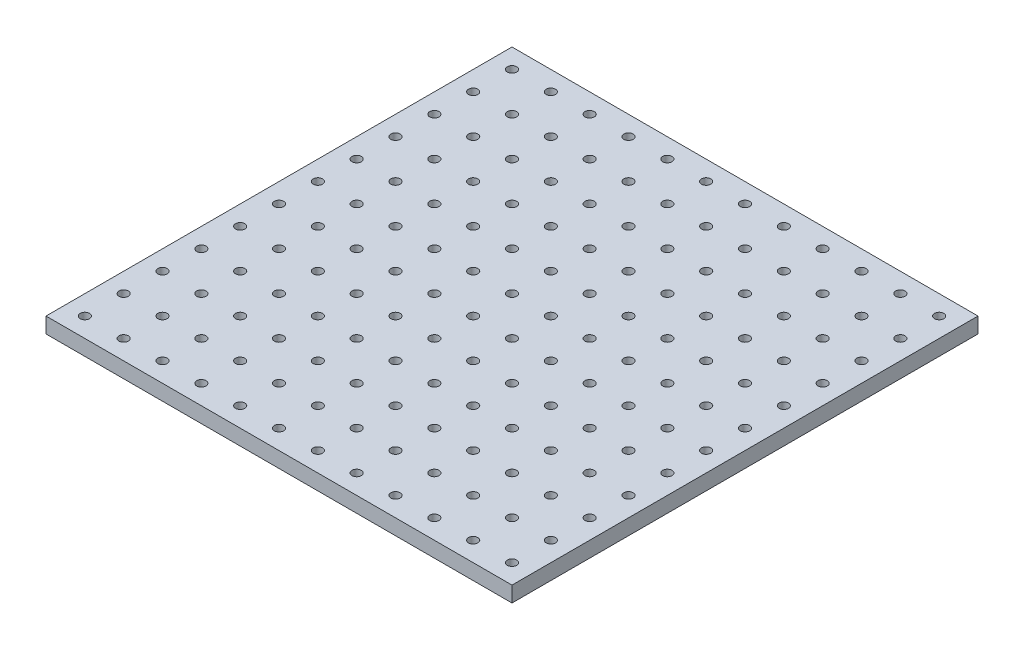
from build123d import *

# Parameters (mm, degrees)
SKETCH_2_W      = 300
SKETCH_2_H      = 300
SKETCH_2_R      = 3
EXTRUDE_2_DEPTH = 10


with BuildPart() as part:
    # 스케치2 → 보스-돌출2 (new body)
    with BuildSketch(Plane(origin=(0, 0, 0), x_dir=(1, 0, 0), z_dir=(0, 1, 0))):
        Rectangle(SKETCH_2_W, SKETCH_2_H)
        with Locations((-137.5, -137.5)):
            Circle(SKETCH_2_R, mode=Mode.SUBTRACT)
        with Locations((-112.5, -137.5)):
            Circle(SKETCH_2_R, mode=Mode.SUBTRACT)
        with Locations((-87.5, -137.5)):
            Circle(SKETCH_2_R, mode=Mode.SUBTRACT)
        with Locations((-62.5, -137.5)):
            Circle(SKETCH_2_R, mode=Mode.SUBTRACT)
        with Locations((-37.5, -137.5)):
            Circle(SKETCH_2_R, mode=Mode.SUBTRACT)
        with Locations((-12.5, -137.5)):
            Circle(SKETCH_2_R, mode=Mode.SUBTRACT)
        with Locations((12.5, -137.5)):
            Circle(SKETCH_2_R, mode=Mode.SUBTRACT)
        with Locations((37.5, -137.5)):
            Circle(SKETCH_2_R, mode=Mode.SUBTRACT)
        with Locations((62.5, -137.5)):
            Circle(SKETCH_2_R, mode=Mode.SUBTRACT)
        with Locations((87.5, -137.5)):
            Circle(SKETCH_2_R, mode=Mode.SUBTRACT)
        with Locations((112.5, -137.5)):
            Circle(SKETCH_2_R, mode=Mode.SUBTRACT)
        with Locations((137.5, -137.5)):
            Circle(SKETCH_2_R, mode=Mode.SUBTRACT)
        with Locations((-112.5, -112.5)):
            Circle(SKETCH_2_R, mode=Mode.SUBTRACT)
        with Locations((-87.5, -112.5)):
            Circle(SKETCH_2_R, mode=Mode.SUBTRACT)
        with Locations((-62.5, -112.5)):
            Circle(SKETCH_2_R, mode=Mode.SUBTRACT)
        with Locations((-37.5, -112.5)):
            Circle(SKETCH_2_R, mode=Mode.SUBTRACT)
        with Locations((-12.5, -112.5)):
            Circle(SKETCH_2_R, mode=Mode.SUBTRACT)
        with Locations((12.5, -112.5)):
            Circle(SKETCH_2_R, mode=Mode.SUBTRACT)
        with Locations((37.5, -112.5)):
            Circle(SKETCH_2_R, mode=Mode.SUBTRACT)
        with Locations((62.5, -112.5)):
            Circle(SKETCH_2_R, mode=Mode.SUBTRACT)
        with Locations((87.5, -112.5)):
            Circle(SKETCH_2_R, mode=Mode.SUBTRACT)
        with Locations((112.5, -112.5)):
            Circle(SKETCH_2_R, mode=Mode.SUBTRACT)
        with Locations((137.5, -112.5)):
            Circle(SKETCH_2_R, mode=Mode.SUBTRACT)
        with Locations((-112.5, -87.5)):
            Circle(SKETCH_2_R, mode=Mode.SUBTRACT)
        with Locations((-87.5, -87.5)):
            Circle(SKETCH_2_R, mode=Mode.SUBTRACT)
        with Locations((-62.5, -87.5)):
            Circle(SKETCH_2_R, mode=Mode.SUBTRACT)
        with Locations((-37.5, -87.5)):
            Circle(SKETCH_2_R, mode=Mode.SUBTRACT)
        with Locations((-12.5, -87.5)):
            Circle(SKETCH_2_R, mode=Mode.SUBTRACT)
        with Locations((12.5, -87.5)):
            Circle(SKETCH_2_R, mode=Mode.SUBTRACT)
        with Locations((37.5, -87.5)):
            Circle(SKETCH_2_R, mode=Mode.SUBTRACT)
        with Locations((62.5, -87.5)):
            Circle(SKETCH_2_R, mode=Mode.SUBTRACT)
        with Locations((87.5, -87.5)):
            Circle(SKETCH_2_R, mode=Mode.SUBTRACT)
        with Locations((112.5, -87.5)):
            Circle(SKETCH_2_R, mode=Mode.SUBTRACT)
        with Locations((137.5, -87.5)):
            Circle(SKETCH_2_R, mode=Mode.SUBTRACT)
        with Locations((-112.5, -62.5)):
            Circle(SKETCH_2_R, mode=Mode.SUBTRACT)
        with Locations((-87.5, -62.5)):
            Circle(SKETCH_2_R, mode=Mode.SUBTRACT)
        with Locations((-62.5, -62.5)):
            Circle(SKETCH_2_R, mode=Mode.SUBTRACT)
        with Locations((-37.5, -62.5)):
            Circle(SKETCH_2_R, mode=Mode.SUBTRACT)
        with Locations((-12.5, -62.5)):
            Circle(SKETCH_2_R, mode=Mode.SUBTRACT)
        with Locations((12.5, -62.5)):
            Circle(SKETCH_2_R, mode=Mode.SUBTRACT)
        with Locations((37.5, -62.5)):
            Circle(SKETCH_2_R, mode=Mode.SUBTRACT)
        with Locations((62.5, -62.5)):
            Circle(SKETCH_2_R, mode=Mode.SUBTRACT)
        with Locations((87.5, -62.5)):
            Circle(SKETCH_2_R, mode=Mode.SUBTRACT)
        with Locations((112.5, -62.5)):
            Circle(SKETCH_2_R, mode=Mode.SUBTRACT)
        with Locations((137.5, -62.5)):
            Circle(SKETCH_2_R, mode=Mode.SUBTRACT)
        with Locations((-112.5, -37.5)):
            Circle(SKETCH_2_R, mode=Mode.SUBTRACT)
        with Locations((-87.5, -37.5)):
            Circle(SKETCH_2_R, mode=Mode.SUBTRACT)
        with Locations((-62.5, -37.5)):
            Circle(SKETCH_2_R, mode=Mode.SUBTRACT)
        with Locations((-37.5, -37.5)):
            Circle(SKETCH_2_R, mode=Mode.SUBTRACT)
        with Locations((-12.5, -37.5)):
            Circle(SKETCH_2_R, mode=Mode.SUBTRACT)
        with Locations((12.5, -37.5)):
            Circle(SKETCH_2_R, mode=Mode.SUBTRACT)
        with Locations((37.5, -37.5)):
            Circle(SKETCH_2_R, mode=Mode.SUBTRACT)
        with Locations((62.5, -37.5)):
            Circle(SKETCH_2_R, mode=Mode.SUBTRACT)
        with Locations((87.5, -37.5)):
            Circle(SKETCH_2_R, mode=Mode.SUBTRACT)
        with Locations((112.5, -37.5)):
            Circle(SKETCH_2_R, mode=Mode.SUBTRACT)
        with Locations((137.5, -37.5)):
            Circle(SKETCH_2_R, mode=Mode.SUBTRACT)
        with Locations((-112.5, -12.5)):
            Circle(SKETCH_2_R, mode=Mode.SUBTRACT)
        with Locations((-87.5, -12.5)):
            Circle(SKETCH_2_R, mode=Mode.SUBTRACT)
        with Locations((-62.5, -12.5)):
            Circle(SKETCH_2_R, mode=Mode.SUBTRACT)
        with Locations((-37.5, -12.5)):
            Circle(SKETCH_2_R, mode=Mode.SUBTRACT)
        with Locations((-12.5, -12.5)):
            Circle(SKETCH_2_R, mode=Mode.SUBTRACT)
        with Locations((12.5, -12.5)):
            Circle(SKETCH_2_R, mode=Mode.SUBTRACT)
        with Locations((37.5, -12.5)):
            Circle(SKETCH_2_R, mode=Mode.SUBTRACT)
        with Locations((62.5, -12.5)):
            Circle(SKETCH_2_R, mode=Mode.SUBTRACT)
        with Locations((87.5, -12.5)):
            Circle(SKETCH_2_R, mode=Mode.SUBTRACT)
        with Locations((112.5, -12.5)):
            Circle(SKETCH_2_R, mode=Mode.SUBTRACT)
        with Locations((137.5, -12.5)):
            Circle(SKETCH_2_R, mode=Mode.SUBTRACT)
        with Locations((-112.5, 12.5)):
            Circle(SKETCH_2_R, mode=Mode.SUBTRACT)
        with Locations((-87.5, 12.5)):
            Circle(SKETCH_2_R, mode=Mode.SUBTRACT)
        with Locations((-62.5, 12.5)):
            Circle(SKETCH_2_R, mode=Mode.SUBTRACT)
        with Locations((-37.5, 12.5)):
            Circle(SKETCH_2_R, mode=Mode.SUBTRACT)
        with Locations((-12.5, 12.5)):
            Circle(SKETCH_2_R, mode=Mode.SUBTRACT)
        with Locations((12.5, 12.5)):
            Circle(SKETCH_2_R, mode=Mode.SUBTRACT)
        with Locations((37.5, 12.5)):
            Circle(SKETCH_2_R, mode=Mode.SUBTRACT)
        with Locations((62.5, 12.5)):
            Circle(SKETCH_2_R, mode=Mode.SUBTRACT)
        with Locations((87.5, 12.5)):
            Circle(SKETCH_2_R, mode=Mode.SUBTRACT)
        with Locations((112.5, 12.5)):
            Circle(SKETCH_2_R, mode=Mode.SUBTRACT)
        with Locations((137.5, 12.5)):
            Circle(SKETCH_2_R, mode=Mode.SUBTRACT)
        with Locations((-112.5, 37.5)):
            Circle(SKETCH_2_R, mode=Mode.SUBTRACT)
        with Locations((-87.5, 37.5)):
            Circle(SKETCH_2_R, mode=Mode.SUBTRACT)
        with Locations((-62.5, 37.5)):
            Circle(SKETCH_2_R, mode=Mode.SUBTRACT)
        with Locations((-37.5, 37.5)):
            Circle(SKETCH_2_R, mode=Mode.SUBTRACT)
        with Locations((-12.5, 37.5)):
            Circle(SKETCH_2_R, mode=Mode.SUBTRACT)
        with Locations((12.5, 37.5)):
            Circle(SKETCH_2_R, mode=Mode.SUBTRACT)
        with Locations((37.5, 37.5)):
            Circle(SKETCH_2_R, mode=Mode.SUBTRACT)
        with Locations((62.5, 37.5)):
            Circle(SKETCH_2_R, mode=Mode.SUBTRACT)
        with Locations((87.5, 37.5)):
            Circle(SKETCH_2_R, mode=Mode.SUBTRACT)
        with Locations((112.5, 37.5)):
            Circle(SKETCH_2_R, mode=Mode.SUBTRACT)
        with Locations((137.5, 37.5)):
            Circle(SKETCH_2_R, mode=Mode.SUBTRACT)
        with Locations((-112.5, 62.5)):
            Circle(SKETCH_2_R, mode=Mode.SUBTRACT)
        with Locations((-87.5, 62.5)):
            Circle(SKETCH_2_R, mode=Mode.SUBTRACT)
        with Locations((-62.5, 62.5)):
            Circle(SKETCH_2_R, mode=Mode.SUBTRACT)
        with Locations((-37.5, 62.5)):
            Circle(SKETCH_2_R, mode=Mode.SUBTRACT)
        with Locations((-12.5, 62.5)):
            Circle(SKETCH_2_R, mode=Mode.SUBTRACT)
        with Locations((12.5, 62.5)):
            Circle(SKETCH_2_R, mode=Mode.SUBTRACT)
        with Locations((37.5, 62.5)):
            Circle(SKETCH_2_R, mode=Mode.SUBTRACT)
        with Locations((62.5, 62.5)):
            Circle(SKETCH_2_R, mode=Mode.SUBTRACT)
        with Locations((87.5, 62.5)):
            Circle(SKETCH_2_R, mode=Mode.SUBTRACT)
        with Locations((112.5, 62.5)):
            Circle(SKETCH_2_R, mode=Mode.SUBTRACT)
        with Locations((137.5, 62.5)):
            Circle(SKETCH_2_R, mode=Mode.SUBTRACT)
        with Locations((-112.5, 87.5)):
            Circle(SKETCH_2_R, mode=Mode.SUBTRACT)
        with Locations((-87.5, 87.5)):
            Circle(SKETCH_2_R, mode=Mode.SUBTRACT)
        with Locations((-62.5, 87.5)):
            Circle(SKETCH_2_R, mode=Mode.SUBTRACT)
        with Locations((-37.5, 87.5)):
            Circle(SKETCH_2_R, mode=Mode.SUBTRACT)
        with Locations((-12.5, 87.5)):
            Circle(SKETCH_2_R, mode=Mode.SUBTRACT)
        with Locations((12.5, 87.5)):
            Circle(SKETCH_2_R, mode=Mode.SUBTRACT)
        with Locations((37.5, 87.5)):
            Circle(SKETCH_2_R, mode=Mode.SUBTRACT)
        with Locations((62.5, 87.5)):
            Circle(SKETCH_2_R, mode=Mode.SUBTRACT)
        with Locations((87.5, 87.5)):
            Circle(SKETCH_2_R, mode=Mode.SUBTRACT)
        with Locations((112.5, 87.5)):
            Circle(SKETCH_2_R, mode=Mode.SUBTRACT)
        with Locations((137.5, 87.5)):
            Circle(SKETCH_2_R, mode=Mode.SUBTRACT)
        with Locations((-112.5, 112.5)):
            Circle(SKETCH_2_R, mode=Mode.SUBTRACT)
        with Locations((-87.5, 112.5)):
            Circle(SKETCH_2_R, mode=Mode.SUBTRACT)
        with Locations((-62.5, 112.5)):
            Circle(SKETCH_2_R, mode=Mode.SUBTRACT)
        with Locations((-37.5, 112.5)):
            Circle(SKETCH_2_R, mode=Mode.SUBTRACT)
        with Locations((-12.5, 112.5)):
            Circle(SKETCH_2_R, mode=Mode.SUBTRACT)
        with Locations((12.5, 112.5)):
            Circle(SKETCH_2_R, mode=Mode.SUBTRACT)
        with Locations((37.5, 112.5)):
            Circle(SKETCH_2_R, mode=Mode.SUBTRACT)
        with Locations((62.5, 112.5)):
            Circle(SKETCH_2_R, mode=Mode.SUBTRACT)
        with Locations((87.5, 112.5)):
            Circle(SKETCH_2_R, mode=Mode.SUBTRACT)
        with Locations((112.5, 112.5)):
            Circle(SKETCH_2_R, mode=Mode.SUBTRACT)
        with Locations((137.5, 112.5)):
            Circle(SKETCH_2_R, mode=Mode.SUBTRACT)
        with Locations((-112.5, 137.5)):
            Circle(SKETCH_2_R, mode=Mode.SUBTRACT)
        with Locations((-87.5, 137.5)):
            Circle(SKETCH_2_R, mode=Mode.SUBTRACT)
        with Locations((-62.5, 137.5)):
            Circle(SKETCH_2_R, mode=Mode.SUBTRACT)
        with Locations((-37.5, 137.5)):
            Circle(SKETCH_2_R, mode=Mode.SUBTRACT)
        with Locations((-12.5, 137.5)):
            Circle(SKETCH_2_R, mode=Mode.SUBTRACT)
        with Locations((12.5, 137.5)):
            Circle(SKETCH_2_R, mode=Mode.SUBTRACT)
        with Locations((37.5, 137.5)):
            Circle(SKETCH_2_R, mode=Mode.SUBTRACT)
        with Locations((62.5, 137.5)):
            Circle(SKETCH_2_R, mode=Mode.SUBTRACT)
        with Locations((87.5, 137.5)):
            Circle(SKETCH_2_R, mode=Mode.SUBTRACT)
        with Locations((112.5, 137.5)):
            Circle(SKETCH_2_R, mode=Mode.SUBTRACT)
        with Locations((137.5, 137.5)):
            Circle(SKETCH_2_R, mode=Mode.SUBTRACT)
        with Locations((-137.5, -112.5)):
            Circle(SKETCH_2_R, mode=Mode.SUBTRACT)
        with Locations((-137.5, -87.5)):
            Circle(SKETCH_2_R, mode=Mode.SUBTRACT)
        with Locations((-137.5, -62.5)):
            Circle(SKETCH_2_R, mode=Mode.SUBTRACT)
        with Locations((-137.5, -37.5)):
            Circle(SKETCH_2_R, mode=Mode.SUBTRACT)
        with Locations((-137.5, -12.5)):
            Circle(SKETCH_2_R, mode=Mode.SUBTRACT)
        with Locations((-137.5, 12.5)):
            Circle(SKETCH_2_R, mode=Mode.SUBTRACT)
        with Locations((-137.5, 37.5)):
            Circle(SKETCH_2_R, mode=Mode.SUBTRACT)
        with Locations((-137.5, 62.5)):
            Circle(SKETCH_2_R, mode=Mode.SUBTRACT)
        with Locations((-137.5, 87.5)):
            Circle(SKETCH_2_R, mode=Mode.SUBTRACT)
        with Locations((-137.5, 112.5)):
            Circle(SKETCH_2_R, mode=Mode.SUBTRACT)
        with Locations((-137.5, 137.5)):
            Circle(SKETCH_2_R, mode=Mode.SUBTRACT)
    extrude(amount=EXTRUDE_2_DEPTH)


solid = part.part
